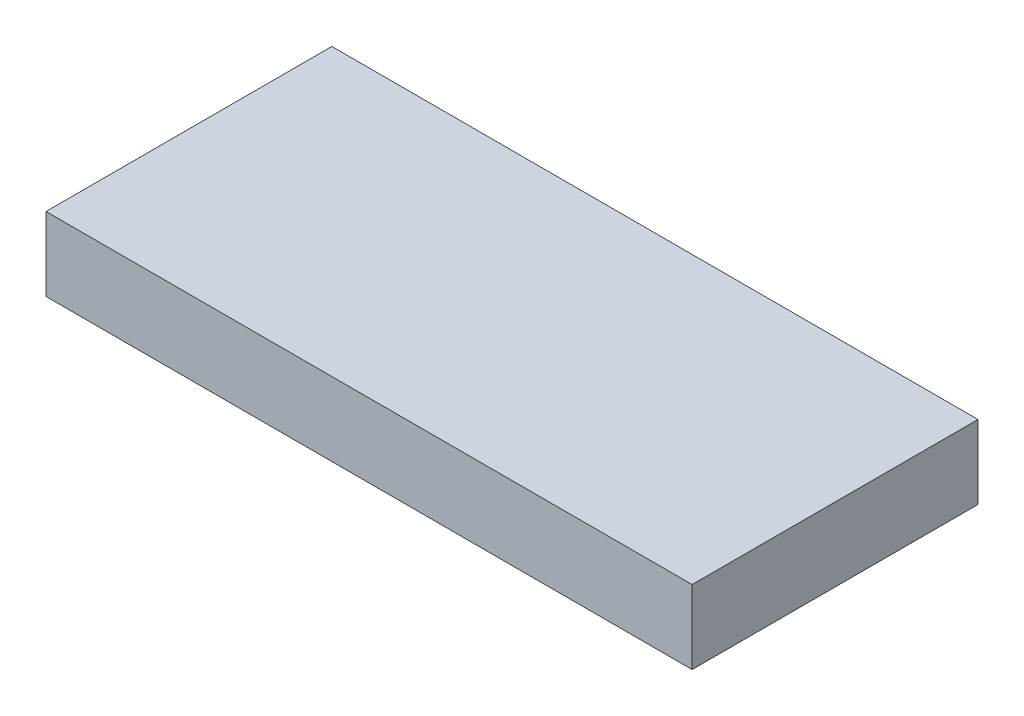
from build123d import *

# Parameters (mm, degrees)
SKETCH1_W           = 165
SKETCH1_H           = 73
BOSS_EXTRUDE1_DEPTH = 18.8


with BuildPart() as part:
    # Sketch1 → Boss-Extrude1 (new body)
    with BuildSketch(Plane(origin=(0, 0, 0), x_dir=(1, 0, 0), z_dir=(0, 1, 0))):
        Rectangle(SKETCH1_W, SKETCH1_H)
    extrude(amount=BOSS_EXTRUDE1_DEPTH)


solid = part.part
